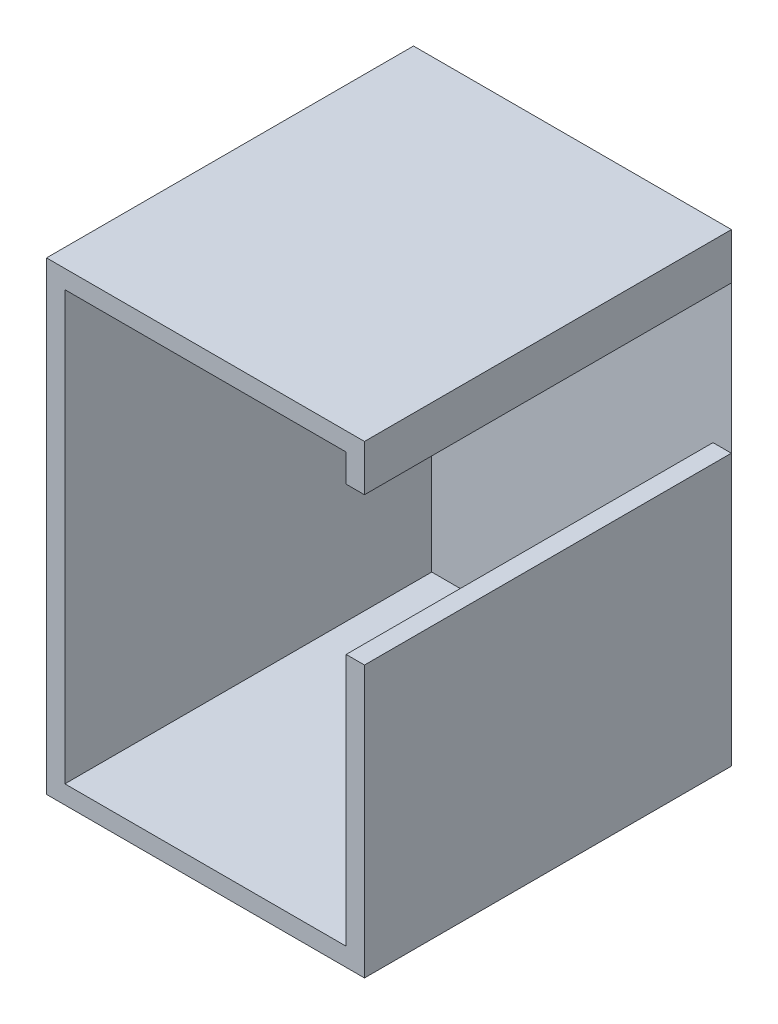
from build123d import *

# Parameters (mm, degrees)
BOSS_EXTRUDE1_DEPTH = 3000
SKETCH2_W           = 2600
SKETCH2_H           = 3800
BOSS_EXTRUDE2_DEPTH = 1


with BuildPart() as part:
    # Sketch1 → Boss-Extrude1 (new body)
    with BuildSketch(Plane.XY):
        Polygon((0, -227.614779849), (150, -227.614779849), (150, 150), (-2450, 150), (-2450, -3650), (150, -3650), (150, -1433.336510226), (0, -1433.336510226), (0, -3500), (-2300, -3500), (-2300, 0), (0, 0), align=None)
    extrude(amount=BOSS_EXTRUDE1_DEPTH)

    # Sketch2 → Boss-Extrude2 (add)
    with BuildSketch(Plane(origin=(0, 0, 0), x_dir=(-1, 0, 0), z_dir=(0, 0, -1))):
        with Locations((1150, -1750)):
            Rectangle(SKETCH2_W, SKETCH2_H)
    extrude(amount=BOSS_EXTRUDE2_DEPTH)


solid = part.part
